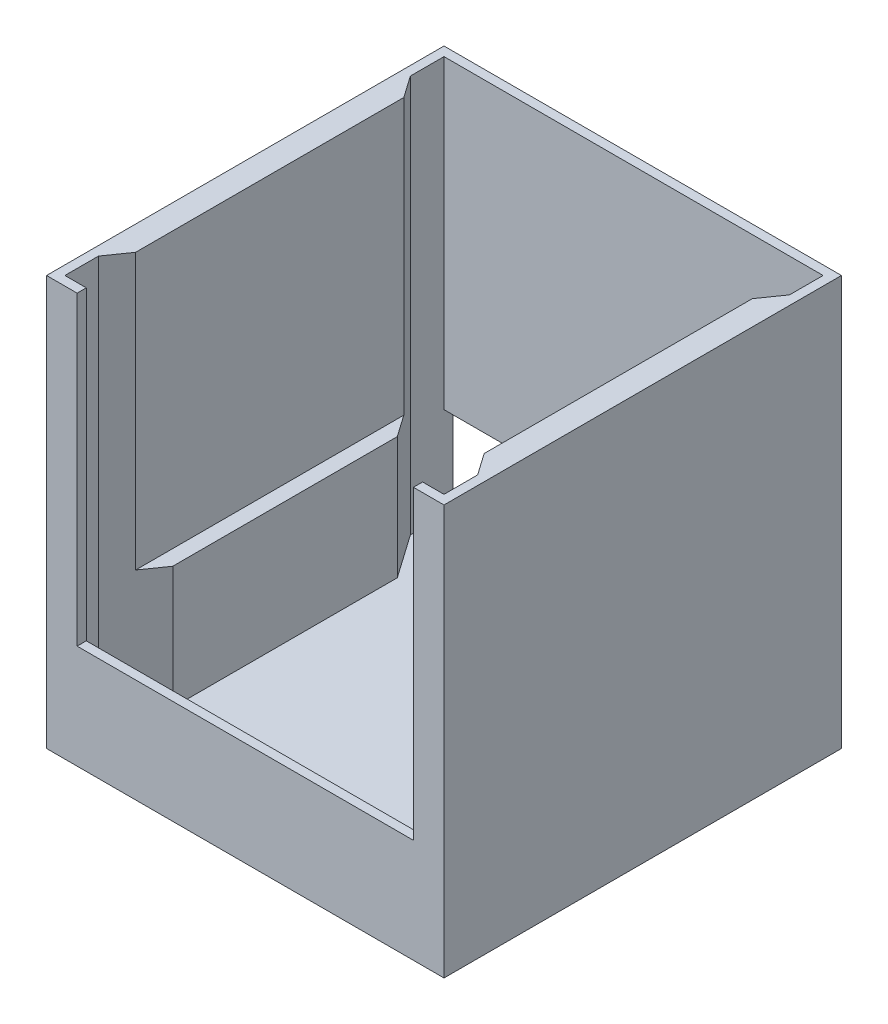
from build123d import *

# Parameters (mm, degrees)
SKETCH1_W           = 165.1
SKETCH1_H           = 165.1
BOSS_EXTRUDE1_DEPTH = 127
BOSS_EXTRUDE2_DEPTH = 38.1
SKETCH5_W           = 165.1
SKETCH5_H           = 165.1
BOSS_EXTRUDE3_DEPTH = 5.08
SKETCH6_W           = 139.7
SKETCH6_H           = 127
CUT_EXTRUDE1_DEPTH  = 12.7
SKETCH1_4_W         = 6.35
SKETCH1_4_H         = 129.54
BOSS_EXTRUDE5_DEPTH = 41.656
SKETCH8_W           = 6.35
SKETCH8_H           = 129.54
BOSS_EXTRUDE6_DEPTH = 50.8
CUT_EXTRUDE2_DEPTH  = 203.205378267


with BuildPart() as part:
    # Sketch1 → Boss-Extrude1 (new body)
    with BuildSketch(Plane(origin=(0, 0, 0), x_dir=(1, 0, 0), z_dir=(0, 1, 0))):
        Rectangle(SKETCH1_W, SKETCH1_H)
        Polygon((78.74, -78.74), (-78.74, -78.74), (-78.74, -64.77), (-72.39, -64.77), (-72.39, 64.77), (-78.74, 64.77), (-78.74, 78.74), (78.74, 78.74), (78.74, 64.77), (72.39, 64.77), (72.39, -64.77), (78.74, -64.77), align=None, mode=Mode.SUBTRACT)
    extrude(amount=BOSS_EXTRUDE1_DEPTH)

    # Sketch4 → Boss-Extrude2 (add)
    with BuildSketch(Plane.XZ):
        Polygon((-82.55, 82.55), (-82.55, -82.55), (-78.74, -82.55), (-78.74, -78.74), (-78.74, -64.77), (-78.74, 64.77), (-78.74, 78.74), (78.74, 78.74), (78.74, 64.77), (78.74, -64.77), (78.74, -78.74), (78.74, -82.55), (82.55, -82.55), (82.55, 82.55), align=None)
    extrude(amount=BOSS_EXTRUDE2_DEPTH)

    # Sketch5 → Boss-Extrude3 (add)
    with BuildSketch(Plane.XZ.offset(38.1)):
        Rectangle(SKETCH5_W, SKETCH5_H)
    extrude(amount=BOSS_EXTRUDE3_DEPTH)

    # Sketch6 → Cut-Extrude1 (cut)
    with BuildSketch(Plane.XY.offset(82.55)):
        with Locations((0, 63.5)):
            Rectangle(SKETCH6_W, SKETCH6_H)
    extrude(amount=-CUT_EXTRUDE1_DEPTH, mode=Mode.SUBTRACT)

    # Sketch1_4 → Boss-Extrude5 (add)
    with BuildSketch(Plane(origin=(0, 0, 0), x_dir=(1, 0, 0), z_dir=(0, 1, 0))):
        with Locations((-75.565, 0)):
            Rectangle(SKETCH1_4_W, SKETCH1_4_H)
        with Locations((75.565, 0)):
            Rectangle(SKETCH1_4_W, SKETCH1_4_H)
    extrude(amount=-BOSS_EXTRUDE5_DEPTH)

    # Sketch8 → Boss-Extrude6 (add)
    with BuildSketch(Plane(origin=(0, -38.1, 0), x_dir=(1, 0, 0), z_dir=(0, 1, 0))):
        with Locations((-69.215, 0)):
            Rectangle(SKETCH8_W, SKETCH8_H)
        with Locations((69.215, 0)):
            Rectangle(SKETCH8_W, SKETCH8_H)
    extrude(amount=BOSS_EXTRUDE6_DEPTH)

    # Sketch9 → Cut-Extrude2 (cut, through all)
    with BuildSketch(Plane(origin=(0, -38.1, 0), x_dir=(1, 0, 0), z_dir=(0, 1, 0))):
        Polygon((-66.04, 64.77), (-78.74, 64.77), (-66.04, 46.632520314), align=None)
        Polygon((-66.04, -46.632520314), (-78.74, -64.77), (-66.04, -64.77), align=None)
        Polygon((66.04, -64.77), (78.74, -64.77), (66.04, -46.632520314), align=None)
        Polygon((78.74, 64.77), (66.04, 64.77), (66.04, 46.632520314), align=None)
    extrude(amount=CUT_EXTRUDE2_DEPTH, mode=Mode.SUBTRACT)


solid = part.part
